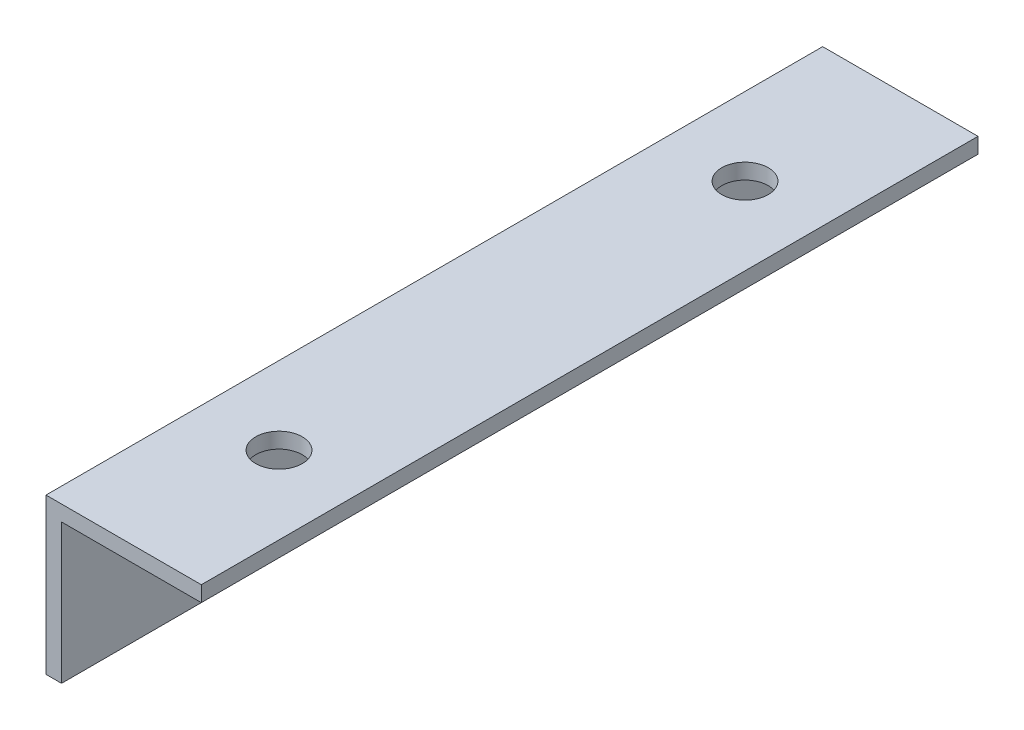
from build123d import *

# Parameters (mm, degrees)
BOSS_EXTRUDE1_DEPTH = 100
SKETCH3_R           = 3
CUT_EXTRUDE1_DEPTH  = 20
SKETCH4_R           = 3
CUT_EXTRUDE2_DEPTH  = 20
SKETCH5_R           = 3
CUT_EXTRUDE3_DEPTH  = 20
SKETCH6_R           = 3
CUT_EXTRUDE4_DEPTH  = 20


with BuildPart() as part:
    # Sketch2 → Boss-Extrude1 (new body)
    with BuildSketch(Plane.XY):
        Polygon((0, 0), (0, 20), (20, 20), (20, 18), (2, 18), (2, 0), align=None)
    extrude(amount=BOSS_EXTRUDE1_DEPTH)

    # Sketch3 → Cut-Extrude1 (cut)
    with BuildSketch(Plane.ZY):
        with Locations((80, 10)):
            Circle(SKETCH3_R)
    extrude(amount=-CUT_EXTRUDE1_DEPTH, mode=Mode.SUBTRACT)

    # Sketch4 → Cut-Extrude2 (cut)
    with BuildSketch(Plane.ZY):
        with Locations((20, 10)):
            Circle(SKETCH4_R)
    extrude(amount=-CUT_EXTRUDE2_DEPTH, mode=Mode.SUBTRACT)

    # Sketch5 → Cut-Extrude3 (cut)
    with BuildSketch(Plane(origin=(0, 20, 0), x_dir=(1, 0, 0), z_dir=(0, 1, 0))):
        with Locations((10, -80)):
            Circle(SKETCH5_R)
    extrude(amount=-CUT_EXTRUDE3_DEPTH, mode=Mode.SUBTRACT)

    # Sketch6 → Cut-Extrude4 (cut)
    with BuildSketch(Plane(origin=(0, 20, 0), x_dir=(1, 0, 0), z_dir=(0, 1, 0))):
        with Locations((10, -20)):
            Circle(SKETCH6_R)
    extrude(amount=-CUT_EXTRUDE4_DEPTH, mode=Mode.SUBTRACT)


solid = part.part
